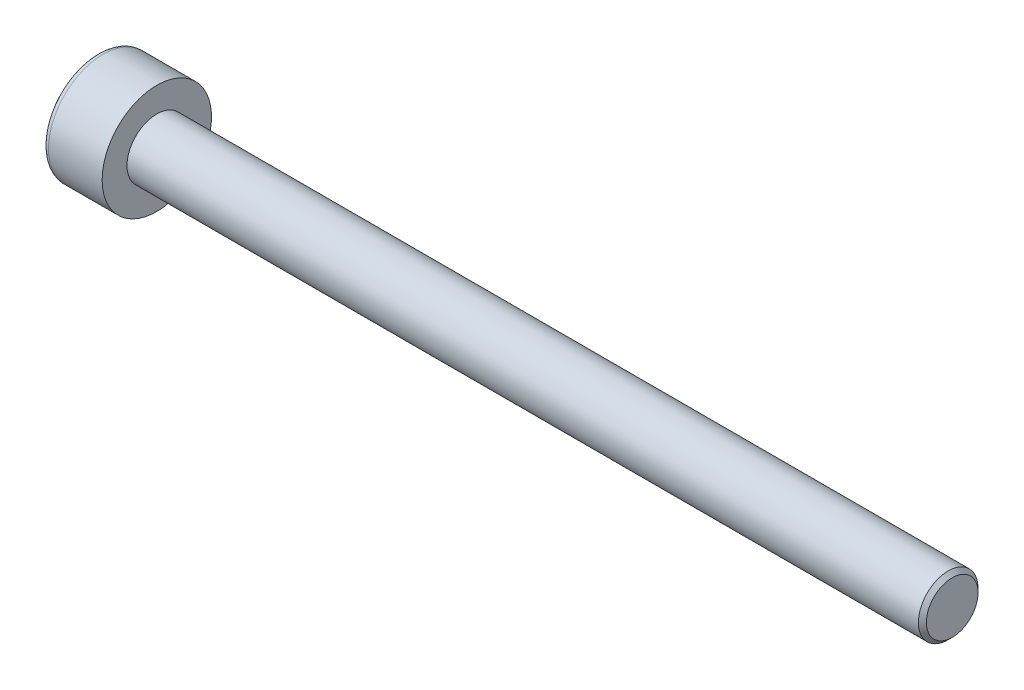
from build123d import *

# Parameters (mm, degrees)
SCHNITT_LINEAR_AUSTRAGEN1_DEPTH = 1.5


with BuildPart() as part:
    # Skizze1 → Rotation1 (revolve)
    with BuildSketch(Plane.XY):
        with BuildLine():
            Line((0, 0), (0, 2.45))
            ThreePointArc((0, 2.45), (0.087867966, 2.662132034), (0.3, 2.75))
            Line((0.3, 2.75), (3, 2.75))
            Line((3, 2.75), (3, 1.5))
            Line((3, 1.5), (42.8, 1.5))
            Line((42.8, 1.5), (43, 1.3))
            Line((43, 1.3), (43, 0))
            Line((43, 0), (0, 0))
        make_face()
    revolve(axis=Axis((0, 0, 0), (1, 0, 0)))

    # Skizze2 → Schnitt-Linear austragen1 (cut)
    with BuildSketch(Plane.ZY):
        Polygon((1.443375673, 0), (0.721687836, 1.25), (-0.721687836, 1.25), (-1.443375673, 0), (-0.721687836, -1.25), (0.721687836, -1.25), align=None)
    extrude(amount=-SCHNITT_LINEAR_AUSTRAGEN1_DEPTH, mode=Mode.SUBTRACT)


solid = part.part
